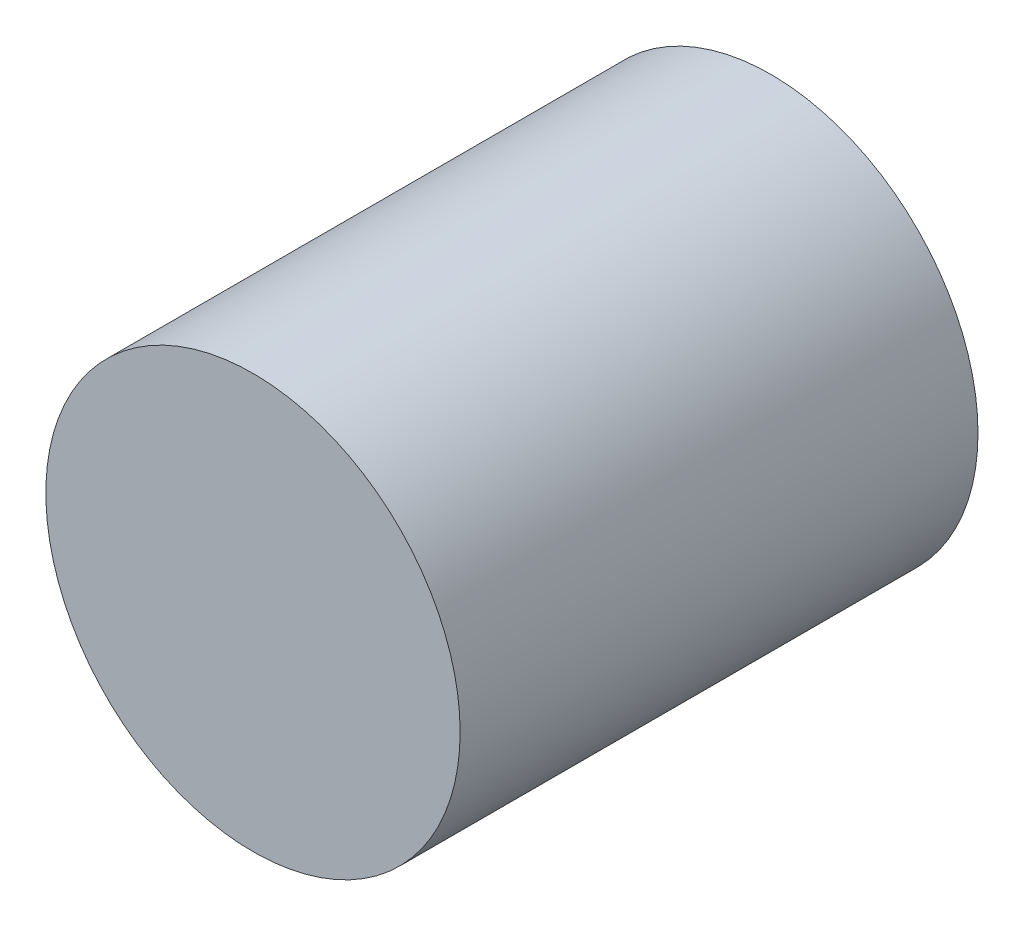
from build123d import *

# Parameters (mm, degrees)
CROQUIS1_R              = 294
SALIENTE_EXTRUIR2_DEPTH = 735


with BuildPart() as part:
    # Croquis1 → Saliente-Extruir2 (new body)
    with BuildSketch(Plane.XY):
        Circle(CROQUIS1_R)
    extrude(amount=SALIENTE_EXTRUIR2_DEPTH)


solid = part.part
